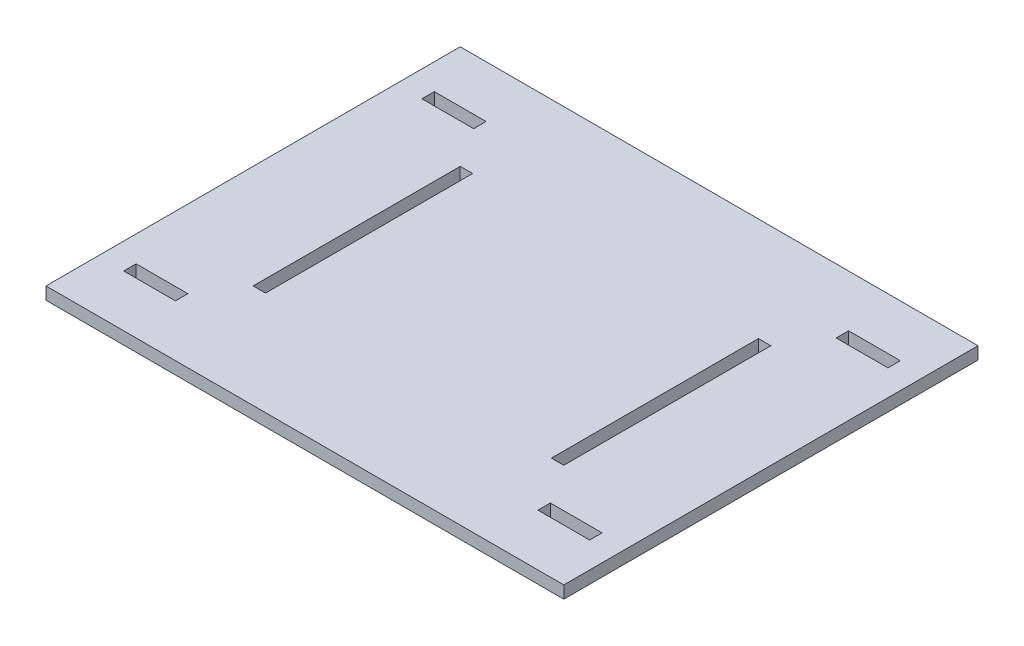
from build123d import *

# Parameters (mm, degrees)
SKETCH1_W                                  = 500
SKETCH1_H                                  = 400
BOSS_EXTRUDE1_DEPTH                        = 12
SKETCH2_W                                  = 12
SKETCH2_H                                  = 200
CUT_EXTRUDE1_DEPTH                         = 12
SKETCH5_W                                  = 50
SKETCH5_H                                  = 12
CUT_EXTRUDE2_DEPTH                         = 12
MIRROR5_AT_THE_SECOND_PLANE_COPY_1_SKETC_W = 50
MIRROR5_AT_THE_SECOND_PLANE_COPY_1_SKETC_H = 12
MIRROR5_AT_THE_SECOND_PLANE_COPY_1_DEPTH   = 12


with BuildPart() as part:
    # Sketch1 → Boss-Extrude1 (new body)
    with BuildSketch(Plane(origin=(0, 0, 0), x_dir=(1, 0, 0), z_dir=(0, 1, 0))):
        Rectangle(SKETCH1_W, SKETCH1_H)
    extrude(amount=BOSS_EXTRUDE1_DEPTH)

    # Sketch2 → Cut-Extrude1 (cut)
    with BuildSketch(Plane(origin=(0, 12, 0), x_dir=(1, 0, 0), z_dir=(0, 1, 0))):
        with Locations((-144, 0)):
            Rectangle(SKETCH2_W, SKETCH2_H)
    cut_extrude1 = extrude(amount=-CUT_EXTRUDE1_DEPTH, mode=Mode.SUBTRACT)

    # Mirror2: Cut-Extrude1 across plane
    add(cut_extrude1.mirror(Plane(origin=(0, 0, 0), x_dir=(0, 0, 1), z_dir=(1, 0, 0))), mode=Mode.SUBTRACT)

    # Sketch5 → Cut-Extrude2 (cut)
    with BuildSketch(Plane(origin=(0, 12, 0), x_dir=(1, 0, 0), z_dir=(0, 1, 0))):
        with Locations((-200, 144)):
            Rectangle(SKETCH5_W, SKETCH5_H)
    cut_extrude2 = extrude(amount=-CUT_EXTRUDE2_DEPTH, mode=Mode.SUBTRACT)

    # Mirror5: Cut-Extrude2 across plane
    add(cut_extrude2.mirror(Plane.XY), mode=Mode.SUBTRACT)

    # Mirror5 at the second plane: Cut-Extrude2 across plane
    add(cut_extrude2.mirror(Plane(origin=(0, 0, 0), x_dir=(0, 0, 1), z_dir=(1, 0, 0))), mode=Mode.SUBTRACT)

    # Mirror5 at the second plane copy 1 sketc → Mirror5 at the second plane copy 1 (cut)
    with BuildSketch(Plane(origin=(0, 12, 0), x_dir=(-1, 0, 0), z_dir=(0, 1, 0))):
        with Locations((-200, 144)):
            Rectangle(MIRROR5_AT_THE_SECOND_PLANE_COPY_1_SKETC_W, MIRROR5_AT_THE_SECOND_PLANE_COPY_1_SKETC_H)
    extrude(amount=-MIRROR5_AT_THE_SECOND_PLANE_COPY_1_DEPTH, mode=Mode.SUBTRACT)


solid = part.part
